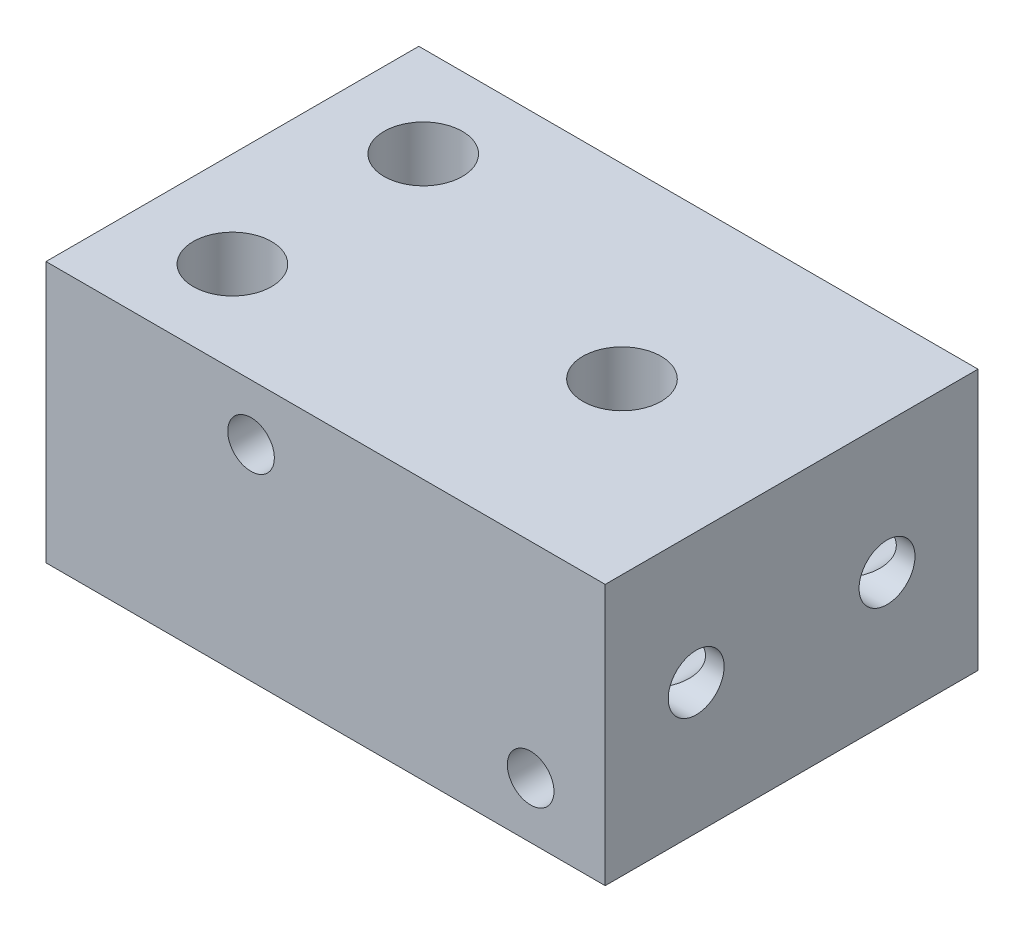
from build123d import *

# Parameters (mm, degrees)
SKETCH1_W                    = 30
SKETCH1_H                    = 14
BOSS_EXTRUDE1_DEPTH          = 10
SKETCH3_R                    = 1
CUT_EXTRUDE2_DEPTH           = 15
M5_TAPPED_HOLE1_D            = 4.2
M5_TAPPED_HOLE1_DEPTH        = 8
M5_TAPPED_HOLE1_TIP          = 1.2618073
F_3_0_3_DIAMETER_HOLE4_D     = 3
F_3_0_3_DIAMETER_HOLE4_DEPTH = 15
F_3_0_3_DIAMETER_HOLE4_TIP   = 0.901290929
F_3_0_3_DIAMETER_HOLE5_D     = 3
F_3_0_3_DIAMETER_HOLE5_DEPTH = 25
F_3_0_3_DIAMETER_HOLE5_TIP   = 0.901290929
M3_TAPPED_HOLE1_D            = 2.5
M3_TAPPED_HOLE1_DEPTH        = 7.5
M3_TAPPED_HOLE1_TIP          = 0.751075774


with BuildPart() as part:
    # Sketch1 → Boss-Extrude1 (new body, symmetric)
    with BuildSketch(Plane.XY):
        Rectangle(SKETCH1_W, SKETCH1_H)
    extrude(amount=BOSS_EXTRUDE1_DEPTH, both=True)

    # Sketch3 → Cut-Extrude2 (cut, through all)
    with BuildSketch(Plane(origin=(0, 7, 0), x_dir=(1, 0, 0), z_dir=(0, 1, 0))):
        with Locations((5.9, 0)):
            Circle(SKETCH3_R)
    extrude(amount=-CUT_EXTRUDE2_DEPTH, mode=Mode.SUBTRACT)

    # M5 Tapped Hole1
    with Locations(Plane(origin=(0, 7, 0), x_dir=(1, 0, 0), z_dir=(0, 1, 0))):
        with Locations((5.9, 0)):
            Hole(M5_TAPPED_HOLE1_D / 2, depth=M5_TAPPED_HOLE1_DEPTH)
            with Locations((0, 0, -(M5_TAPPED_HOLE1_DEPTH + M5_TAPPED_HOLE1_TIP / 2))):  # 118° drill point
                Cone(0, M5_TAPPED_HOLE1_D / 2, M5_TAPPED_HOLE1_TIP, mode=Mode.SUBTRACT)

    # Sketch7 → M5 Tapped Hole2 (revolve, cut)
    with BuildSketch(Plane(origin=(-9.881197846, 7, -5.118802154), x_dir=(0, 0, 1), z_dir=(1, 0, 0))):
        Polygon((0, 0), (0, 11.2618073), (2.1, 10), (2.1, 0), align=None)
    m5_tapped_hole2 = revolve(axis=Axis((-9.881197846, 13.35, -5.118802154), (0, -1, 0)), mode=Mode.SUBTRACT)

    # Mirror1: M5 Tapped Hole2 across plane
    add(m5_tapped_hole2.mirror(Plane.XY), mode=Mode.SUBTRACT)

    # Ø3.0 (3) Diameter Hole4
    with Locations(Plane(origin=(0, 0, -10), x_dir=(-1, 0, 0), z_dir=(0, 0, -1))):
        with Locations((-12.5, 0)):
            Hole(F_3_0_3_DIAMETER_HOLE4_D / 2, depth=F_3_0_3_DIAMETER_HOLE4_DEPTH)
            with Locations((0, 0, -(F_3_0_3_DIAMETER_HOLE4_DEPTH + F_3_0_3_DIAMETER_HOLE4_TIP / 2))):  # 118° drill point
                Cone(0, F_3_0_3_DIAMETER_HOLE4_D / 2, F_3_0_3_DIAMETER_HOLE4_TIP, mode=Mode.SUBTRACT)

    # Ø3.0 (3) Diameter Hole5
    with Locations(Plane(origin=(15, 0, 0), x_dir=(0, 0, -1), z_dir=(1, 0, 0))):
        with Locations((-5.118802154, 0), (5.118802154, 0)):
            Hole(F_3_0_3_DIAMETER_HOLE5_D / 2, depth=F_3_0_3_DIAMETER_HOLE5_DEPTH)
            with Locations((0, 0, -(F_3_0_3_DIAMETER_HOLE5_DEPTH + F_3_0_3_DIAMETER_HOLE5_TIP / 2))):  # 118° drill point
                Cone(0, F_3_0_3_DIAMETER_HOLE5_D / 2, F_3_0_3_DIAMETER_HOLE5_TIP, mode=Mode.SUBTRACT)

    # M3 Tapped Hole1
    with Locations(Plane.XY.offset(10)):
        with Locations((-4, 4), (11, -4)):
            Hole(M3_TAPPED_HOLE1_D / 2, depth=M3_TAPPED_HOLE1_DEPTH)
            with Locations((0, 0, -(M3_TAPPED_HOLE1_DEPTH + M3_TAPPED_HOLE1_TIP / 2))):  # 118° drill point
                Cone(0, M3_TAPPED_HOLE1_D / 2, M3_TAPPED_HOLE1_TIP, mode=Mode.SUBTRACT)


solid = part.part
